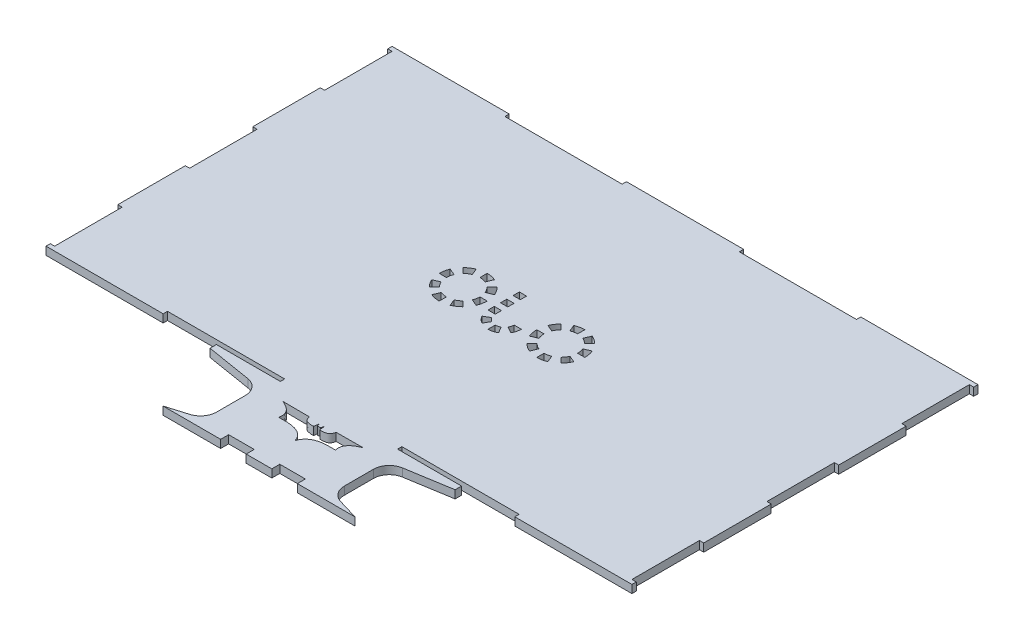
from build123d import *

# Parameters (mm, degrees)
BOSS_EXTRUDE1_DEPTH = 5


with BuildPart() as part:
    # Sketch1 → Boss-Extrude1 (new body)
    with BuildSketch(Plane(origin=(0, 0, 0), x_dir=(1, 0, 0), z_dir=(0, 1, 0))):
        with BuildLine():
            Line((-183.2, 108.2), (-109.92, 108.2))
            Line((-109.92, 108.2), (-109.92, 105.5))
            Line((-109.92, 105.5), (-36.64, 105.5))
            Line((-36.64, 105.5), (-36.64, 108.2))
            Line((-36.64, 108.2), (36.64, 108.2))
            Line((36.64, 108.2), (36.64, 105.5))
            Line((36.64, 105.5), (109.92, 105.5))
            Line((109.92, 105.5), (109.92, 108.2))
            Line((109.92, 108.2), (183.2, 108.2))
            Line((183.2, 108.2), (183.2, 105.5))
            Line((183.2, 105.5), (180.5, 105.5))
            Line((180.5, 105.5), (180.5, 63.3))
            Line((180.5, 63.3), (183.2, 63.3))
            Line((183.2, 63.3), (183.2, 21.1))
            Line((183.2, 21.1), (180.5, 21.1))
            Line((180.5, 21.1), (180.5, -21.1))
            Line((180.5, -21.1), (183.2, -21.1))
            Line((183.2, -21.1), (183.2, -63.3))
            Line((183.2, -63.3), (180.5, -63.3))
            Line((180.5, -63.3), (180.5, -105.5))
            Line((180.5, -105.5), (183.2, -105.5))
            Line((183.2, -105.5), (183.2, -108.2))
            Line((183.2, -108.2), (109.92, -108.2))
            Line((109.92, -108.2), (109.92, -105.5))
            Line((109.92, -105.5), (36.64, -105.5))
            Line((36.64, -105.5), (36.64, -108.2))
            Line((36.64, -108.2), (76.64, -108.2))
            Line((76.64, -108.2), (76.64, -112.2))
            Line((76.64, -112.2), (48.383969685, -116.8270792))
            ThreePointArc((48.383969685, -116.8270792), (42.378966502, -120.22108374), (40, -126.695637657))
            Line((40, -126.695637657), (40, -144.759693491))
            ThreePointArc((40, -144.759693491), (41.977070717, -150.728998787), (47.126521144, -154.337956343))
            Line((47.126521144, -154.337956343), (60, -158.2))
            Line((60, -158.2), (40, -158.2))
            Line((40, -158.2), (24, -158.2))
            Line((24, -158.2), (24, -153.2))
            Line((24, -153.2), (8, -153.2))
            Line((8, -153.2), (8, -158.2))
            Line((8, -158.2), (-8, -158.2))
            Line((-8, -158.2), (-8, -153.2))
            Line((-8, -153.2), (-24, -153.2))
            Line((-24, -153.2), (-24, -158.2))
            Line((-24, -158.2), (-40, -158.2))
            Line((-40, -158.2), (-60, -158.2))
            Line((-60, -158.2), (-47.126521144, -154.337956343))
            ThreePointArc((-47.126521144, -154.337956343), (-41.977070717, -150.728998787), (-40, -144.759693491))
            Line((-40, -144.759693491), (-40, -126.695637657))
            ThreePointArc((-40, -126.695637657), (-42.378966502, -120.22108374), (-48.383969685, -116.8270792))
            Line((-48.383969685, -116.8270792), (-76.64, -112.2))
            Line((-76.64, -112.2), (-76.64, -108.2))
            Line((-76.64, -108.2), (-36.64, -108.2))
            Line((-36.64, -108.2), (-36.64, -105.5))
            Line((-36.64, -105.5), (-109.92, -105.5))
            Line((-109.92, -105.5), (-109.92, -108.2))
            Line((-109.92, -108.2), (-183.2, -108.2))
            Line((-183.2, -108.2), (-183.2, -105.5))
            Line((-183.2, -105.5), (-180.5, -105.5))
            Line((-180.5, -105.5), (-180.5, -63.3))
            Line((-180.5, -63.3), (-183.2, -63.3))
            Line((-183.2, -63.3), (-183.2, -21.1))
            Line((-183.2, -21.1), (-180.5, -21.1))
            Line((-180.5, -21.1), (-180.5, 21.1))
            Line((-180.5, 21.1), (-183.2, 21.1))
            Line((-183.2, 21.1), (-183.2, 63.3))
            Line((-183.2, 63.3), (-180.5, 63.3))
            Line((-180.5, 63.3), (-180.5, 105.5))
            Line((-180.5, 105.5), (-183.2, 105.5))
            Line((-183.2, 105.5), (-183.2, 108.2))
        make_face()
        with BuildLine():
            Line((0.9301176, -120.716600974), (0, -120.68082722))
            Line((0, -120.68082722), (-0.9301176, -120.716600974))
            Line((-0.9301176, -120.716600974), (-1.4468496, -118.933875574))
            Line((-1.4468496, -118.933875574), (-1.505337966, -118.732090711))
            Line((-1.505337966, -118.732090711), (-1.5243594, -118.908038974))
            add(Edge.make_bspline(
                [(-2.0927646, -122.111777374), (-2.0066426, -121.999818774), (-1.859073837, -121.914980184), (-1.8343986, -121.775901574), (-1.666428749, -120.829162413), (-1.6277058, -119.863993174), (-1.5243594, -118.908038974)],
                knots=[0, 0, 0, 0, 1, 1, 1, 2, 2, 2, 2], degree=3))
            add(Edge.make_bspline(
                [(-8.3452218, -118.287960574), (-8.1729778, -118.856365774), (-8.075779611, -119.453175974), (-7.8284898, -119.993176174), (-7.648412968, -120.386405174), (-7.396003023, -120.758010223), (-7.0792284, -121.052476774), (-6.770919603, -121.339073684), (-6.396966748, -121.576394249), (-5.9940912, -121.698391774), (-5.156587311, -121.952002107), (-4.280620327, -122.071245104), (-3.4104312, -122.163450574), (-2.973318406, -122.209767162), (-2.5319868, -122.129001774), (-2.0927646, -122.111777374)],
                knots=[0, 0, 0, 0, 1, 1, 1, 2, 2, 2, 3, 3, 3, 4, 4, 4, 5, 5, 5, 5], degree=3))
            Line((-8.3452218, -118.287960574), (-25.0098288, -118.210450774))
            add(Edge.make_bspline(
                [(-17.7239076, -128.157541774), (-17.6463978, -127.503014574), (-17.486801223, -126.8530449), (-17.4913782, -126.193960174), (-17.495488714, -125.602046218), (-17.572706856, -125.001904806), (-17.7497442, -124.437071374), (-17.938674268, -123.834294492), (-18.223243755, -123.255529036), (-18.5765154, -122.731855774), (-18.962093872, -122.160292392), (-19.432781213, -121.642214377), (-19.9458552, -121.181659774), (-20.53296266, -120.654649929), (-21.178318096, -120.187467606), (-21.8577636, -119.786483374), (-22.869428608, -119.189435173), (-23.975534695, -118.767378369), (-25.0098288, -118.210450774)],
                knots=[0, 0, 0, 0, 1, 1, 1, 2, 2, 2, 3, 3, 3, 4, 4, 4, 5, 5, 5, 6, 6, 6, 6], degree=3))
            add(Edge.make_bspline(
                [(0, -135.727665574), (-0.258366, -135.081750574), (-0.446586906, -134.403141283), (-0.775098, -133.789920574), (-1.096611928, -133.189761242), (-1.489704454, -132.623203353), (-1.937745, -132.110541574), (-2.391023881, -131.591885932), (-2.905578598, -131.121252413), (-3.4621044, -130.715365174), (-4.057630696, -130.281033966), (-4.699347279, -129.901244204), (-5.3740128, -129.604391374), (-6.21408481, -129.23475969), (-7.091056719, -128.940135618), (-7.9835094, -128.725946974), (-9.035354612, -128.473504123), (-10.109700417, -128.304069497), (-11.1872478, -128.209214974), (-12.58604985, -128.086080991), (-13.995132408, -128.060594987), (-15.3986136, -128.105868574), (-16.173499897, -128.130864906), (-16.9488096, -128.140317374), (-17.7239076, -128.157541774)],
                knots=[0, 0, 0, 0, 1, 1, 1, 2, 2, 2, 3, 3, 3, 4, 4, 4, 5, 5, 5, 6, 6, 6, 7, 7, 7, 8, 8, 8, 8], degree=3))
            add(Edge.make_bspline(
                [(0, -135.727665574), (0.258366, -135.081750574), (0.446586906, -134.403141283), (0.775098, -133.789920574), (1.096611928, -133.189761242), (1.489704454, -132.623203353), (1.937745, -132.110541574), (2.391023881, -131.591885932), (2.905578598, -131.121252413), (3.4621044, -130.715365174), (4.057630696, -130.281033966), (4.699347279, -129.901244204), (5.3740128, -129.604391374), (6.21408481, -129.23475969), (7.091056719, -128.940135618), (7.9835094, -128.725946974), (9.035354612, -128.473504123), (10.109700417, -128.304069497), (11.1872478, -128.209214974), (12.58604985, -128.086080991), (13.995132408, -128.060594987), (15.3986136, -128.105868574), (16.173499897, -128.130864906), (16.9488096, -128.140317374), (17.7239076, -128.157541774)],
                knots=[0, 0, 0, 0, 1, 1, 1, 2, 2, 2, 3, 3, 3, 4, 4, 4, 5, 5, 5, 6, 6, 6, 7, 7, 7, 8, 8, 8, 8], degree=3))
            add(Edge.make_bspline(
                [(17.7239076, -128.157541774), (17.6463978, -127.503014574), (17.486801223, -126.8530449), (17.4913782, -126.193960174), (17.495488714, -125.602046218), (17.572706856, -125.001904806), (17.7497442, -124.437071374), (17.938674268, -123.834294492), (18.223243755, -123.255529036), (18.5765154, -122.731855774), (18.962093872, -122.160292392), (19.432781213, -121.642214377), (19.9458552, -121.181659774), (20.53296266, -120.654649929), (21.178318096, -120.187467606), (21.8577636, -119.786483374), (22.869428608, -119.189435173), (23.975534695, -118.767378369), (25.0098288, -118.210450774)],
                knots=[0, 0, 0, 0, 1, 1, 1, 2, 2, 2, 3, 3, 3, 4, 4, 4, 5, 5, 5, 6, 6, 6, 6], degree=3))
            Line((25.0098288, -118.210450774), (8.3452218, -118.287960574))
            add(Edge.make_bspline(
                [(8.3452218, -118.287960574), (8.1729778, -118.856365774), (8.075779611, -119.453175974), (7.8284898, -119.993176174), (7.648412968, -120.386405174), (7.396003023, -120.758010223), (7.0792284, -121.052476774), (6.770919603, -121.339073684), (6.396966748, -121.576394249), (5.9940912, -121.698391774), (5.156587311, -121.952002107), (4.280620327, -122.071245104), (3.4104312, -122.163450574), (2.973318406, -122.209767162), (2.5319868, -122.129001774), (2.0927646, -122.111777374)],
                knots=[0, 0, 0, 0, 1, 1, 1, 2, 2, 2, 3, 3, 3, 4, 4, 4, 5, 5, 5, 5], degree=3))
            add(Edge.make_bspline(
                [(2.0927646, -122.111777374), (2.0066426, -121.999818774), (1.859073837, -121.914980184), (1.8343986, -121.775901574), (1.666428749, -120.829162413), (1.6277058, -119.863993174), (1.5243594, -118.908038974)],
                knots=[0, 0, 0, 0, 1, 1, 1, 2, 2, 2, 2], degree=3))
            Line((1.5243594, -118.908038974), (1.505337966, -118.732090711))
            Line((1.505337966, -118.732090711), (1.4468496, -118.933875574))
            Line((1.4468496, -118.933875574), (0.9301176, -120.716600974))
        make_face(mode=Mode.SUBTRACT)
        Polygon((-10.416027214, 3.248752874), (-10.416027214, 7.165835249), (-5.901936844, 7.165835249), (-5.905104227, 3.248752874), align=None, mode=Mode.SUBTRACT)
        Polygon((-10.416027214, 11.082917625), (-10.416027214, 15), (-5.895602079, 15), (-5.898769461, 11.082917625), align=None, mode=Mode.SUBTRACT)
        with BuildLine():
            Line((-9.020736962, -9.792705988), (-5.119649128, -7.540411877))
            ThreePointArc((-5.119649128, -7.540411877), (-4.180440069, -8.764412954), (-2.956438992, -9.703622014))
            Line((-2.956438992, -9.703622014), (-5.208733103, -13.604709848))
            ThreePointArc((-5.208733103, -13.604709848), (-7.365664947, -11.949637832), (-9.020736962, -9.792705988))
        make_face(mode=Mode.SUBTRACT)
        with BuildLine():
            Line((-0.001438992, -10.495411877), (-0.001438992, -15.000000099))
            ThreePointArc((-0.001438992, -15.000000099), (2.694054787, -14.645131611), (5.205855119, -13.604709848))
            Line((5.205855119, -13.604709848), (2.953561008, -9.703622014))
            ThreePointArc((2.953561008, -9.703622014), (1.528181564, -10.294033511), (-0.001438992, -10.495411877))
        make_face(mode=Mode.SUBTRACT)
        with BuildLine():
            Line((5.116771144, -7.540411877), (9.017858978, -9.792705988))
            ThreePointArc((9.017858978, -9.792705988), (10.058280742, -7.280905656), (10.41314923, -4.585411877))
            Line((10.41314923, -4.585411877), (5.908561008, -4.585411877))
            ThreePointArc((5.908561008, -4.585411877), (5.707182641, -6.115032434), (5.116771144, -7.540411877))
        make_face(mode=Mode.SUBTRACT)
        Polygon((-5.911438992, -4.585411877), (-10.416027214, -4.585411877), (-10.416027214, -0.668329502), (-5.908271609, -0.668329502), align=None, mode=Mode.SUBTRACT)
        with BuildLine():
            Line((-24.787499543, -13.858192988), (-26.509574989, -9.700735091))
            ThreePointArc((-26.509574989, -9.700735091), (-24.694263582, -8.730430929), (-23.103129826, -7.424621202))
            Line((-23.103129826, -7.424621202), (-19.921149311, -10.606601718))
            ThreePointArc((-19.921149311, -10.606601718), (-22.194197533, -12.472044185), (-24.787499543, -13.858192988))
        make_face(mode=Mode.SUBTRACT)
        with BuildLine():
            Line((-15.527751029, 0), (-20.027751029, 0))
            ThreePointArc((-20.027751029, 0), (-20.229505584, -2.048448381), (-20.827015937, -4.01817604))
            Line((-20.827015937, -4.01817604), (-16.669558041, -5.740251485))
            ThreePointArc((-16.669558041, -5.740251485), (-15.815971823, -2.92635483), (-15.527751029, 0))
        make_face(mode=Mode.SUBTRACT)
        with BuildLine():
            Line((-19.921149311, 10.606601718), (-23.103129826, 7.424621202))
            ThreePointArc((-23.103129826, 7.424621202), (-21.7973201, 5.833487447), (-20.827015937, 4.01817604))
            Line((-20.827015937, 4.01817604), (-16.669558041, 5.740251485))
            ThreePointArc((-16.669558041, 5.740251485), (-18.055706844, 8.333553495), (-19.921149311, 10.606601718))
        make_face(mode=Mode.SUBTRACT)
        with BuildLine():
            Line((-30.527751029, 15), (-30.527751029, 10.5))
            ThreePointArc((-30.527751029, 10.5), (-28.479302648, 10.298245444), (-26.509574989, 9.700735091))
            Line((-26.509574989, 9.700735091), (-24.787499543, 13.858192988))
            ThreePointArc((-24.787499543, 13.858192988), (-27.601396198, 14.711779206), (-30.527751029, 15))
        make_face(mode=Mode.SUBTRACT)
        with BuildLine():
            Line((-37.952372231, 7.424621202), (-41.134352746, 10.606601718))
            ThreePointArc((-41.134352746, 10.606601718), (-38.861304524, 12.472044185), (-36.268002514, 13.858192988))
            Line((-36.268002514, 13.858192988), (-34.545927069, 9.700735091))
            ThreePointArc((-34.545927069, 9.700735091), (-36.361238475, 8.730430929), (-37.952372231, 7.424621202))
        make_face(mode=Mode.SUBTRACT)
        with BuildLine():
            Line((-41.027751029, 0), (-45.527751029, 0))
            ThreePointArc((-45.527751029, 0), (-45.239530235, 2.92635483), (-44.385944016, 5.740251485))
            Line((-44.385944016, 5.740251485), (-40.22848612, 4.01817604))
            ThreePointArc((-40.22848612, 4.01817604), (-40.825996473, 2.048448381), (-41.027751029, 0))
        make_face(mode=Mode.SUBTRACT)
        with BuildLine():
            Line((-37.952372231, -7.424621202), (-41.134352746, -10.606601718))
            ThreePointArc((-41.134352746, -10.606601718), (-42.999795213, -8.333553495), (-44.385944016, -5.740251485))
            Line((-44.385944016, -5.740251485), (-40.22848612, -4.01817604))
            ThreePointArc((-40.22848612, -4.01817604), (-39.258181958, -5.833487447), (-37.952372231, -7.424621202))
        make_face(mode=Mode.SUBTRACT)
        with BuildLine():
            Line((-30.527751029, -10.5), (-30.527751029, -15))
            ThreePointArc((-30.527751029, -15), (-33.454105859, -14.711779206), (-36.268002514, -13.858192988))
            Line((-36.268002514, -13.858192988), (-34.545927069, -9.700735091))
            ThreePointArc((-34.545927069, -9.700735091), (-32.57619941, -10.298245444), (-30.527751029, -10.5))
        make_face(mode=Mode.SUBTRACT)
        with BuildLine():
            Line((24.787499543, -13.858192988), (26.509574989, -9.700735091))
            ThreePointArc((26.509574989, -9.700735091), (24.694263582, -8.730430929), (23.103129826, -7.424621202))
            Line((23.103129826, -7.424621202), (19.921149311, -10.606601718))
            ThreePointArc((19.921149311, -10.606601718), (22.194197533, -12.472044185), (24.787499543, -13.858192988))
        make_face(mode=Mode.SUBTRACT)
        with BuildLine():
            Line((30.527751029, -10.5), (30.527751029, -15))
            ThreePointArc((30.527751029, -15), (33.454105859, -14.711779206), (36.268002514, -13.858192988))
            Line((36.268002514, -13.858192988), (34.545927069, -9.700735091))
            ThreePointArc((34.545927069, -9.700735091), (32.57619941, -10.298245444), (30.527751029, -10.5))
        make_face(mode=Mode.SUBTRACT)
        with BuildLine():
            Line((37.952372231, -7.424621202), (41.134352746, -10.606601718))
            ThreePointArc((41.134352746, -10.606601718), (42.999795213, -8.333553495), (44.385944016, -5.740251485))
            Line((44.385944016, -5.740251485), (40.22848612, -4.01817604))
            ThreePointArc((40.22848612, -4.01817604), (39.258181958, -5.833487447), (37.952372231, -7.424621202))
        make_face(mode=Mode.SUBTRACT)
        with BuildLine():
            Line((41.027751029, 0), (45.527751029, 0))
            ThreePointArc((45.527751029, 0), (45.239530235, 2.92635483), (44.385944016, 5.740251485))
            Line((44.385944016, 5.740251485), (40.22848612, 4.01817604))
            ThreePointArc((40.22848612, 4.01817604), (40.825996473, 2.048448381), (41.027751029, 0))
        make_face(mode=Mode.SUBTRACT)
        with BuildLine():
            Line((37.952372231, 7.424621202), (41.134352746, 10.606601718))
            ThreePointArc((41.134352746, 10.606601718), (38.861304524, 12.472044185), (36.268002514, 13.858192988))
            Line((36.268002514, 13.858192988), (34.545927069, 9.700735091))
            ThreePointArc((34.545927069, 9.700735091), (36.361238475, 8.730430929), (37.952372231, 7.424621202))
        make_face(mode=Mode.SUBTRACT)
        with BuildLine():
            Line((30.527751029, 15), (30.527751029, 10.5))
            ThreePointArc((30.527751029, 10.5), (28.479302648, 10.298245444), (26.509574989, 9.700735091))
            Line((26.509574989, 9.700735091), (24.787499543, 13.858192988))
            ThreePointArc((24.787499543, 13.858192988), (27.601396198, 14.711779206), (30.527751029, 15))
        make_face(mode=Mode.SUBTRACT)
        with BuildLine():
            Line((19.921149311, 10.606601718), (23.103129826, 7.424621202))
            ThreePointArc((23.103129826, 7.424621202), (21.7973201, 5.833487447), (20.827015937, 4.01817604))
            Line((20.827015937, 4.01817604), (16.669558041, 5.740251485))
            ThreePointArc((16.669558041, 5.740251485), (18.055706844, 8.333553495), (19.921149311, 10.606601718))
        make_face(mode=Mode.SUBTRACT)
        with BuildLine():
            Line((15.527751029, 0), (20.027751029, 0))
            ThreePointArc((20.027751029, 0), (20.229505584, -2.048448381), (20.827015937, -4.01817604))
            Line((20.827015937, -4.01817604), (16.669558041, -5.740251485))
            ThreePointArc((16.669558041, -5.740251485), (15.815971823, -2.92635483), (15.527751029, 0))
        make_face(mode=Mode.SUBTRACT)
    extrude(amount=BOSS_EXTRUDE1_DEPTH)


solid = part.part
